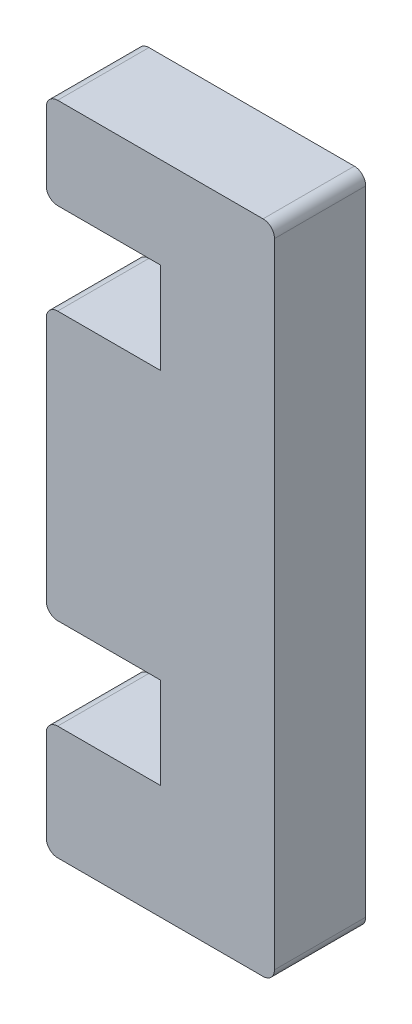
from build123d import *

# Parameters (mm, degrees)
BOSS_EXTRUDE1_DEPTH = 8


with BuildPart() as part:
    # Sketch1 → Boss-Extrude1 (new body)
    with BuildSketch(Plane.XY):
        with BuildLine():
            Line((1, 0), (19, 0))
            ThreePointArc((19, 0), (19.707106781, 0.292893219), (20, 1))
            Line((20, 1), (20, 56.5))
            ThreePointArc((20, 56.5), (19.707106781, 57.207106781), (19, 57.5))
            Line((19, 57.5), (1, 57.5))
            ThreePointArc((1, 57.5), (0.292893219, 57.207106781), (0, 56.5))
            Line((0, 56.5), (0, 50.5))
            ThreePointArc((0, 50.5), (0.292893219, 49.792893219), (1, 49.5))
            Line((1, 49.5), (10, 49.5))
            Line((10, 49.5), (10, 41.5))
            Line((10, 41.5), (1, 41.5))
            ThreePointArc((1, 41.5), (0.292893219, 41.207106781), (0, 40.5))
            Line((0, 40.5), (0, 19))
            ThreePointArc((0, 19), (0.292893219, 18.292893219), (1, 18))
            Line((1, 18), (10, 18))
            Line((10, 18), (10, 10))
            Line((10, 10), (1, 10))
            ThreePointArc((1, 10), (0.292893219, 9.707106781), (0, 9))
            Line((0, 9), (0, 1))
            ThreePointArc((0, 1), (0.292893219, 0.292893219), (1, 0))
        make_face()
    extrude(amount=BOSS_EXTRUDE1_DEPTH)


solid = part.part
